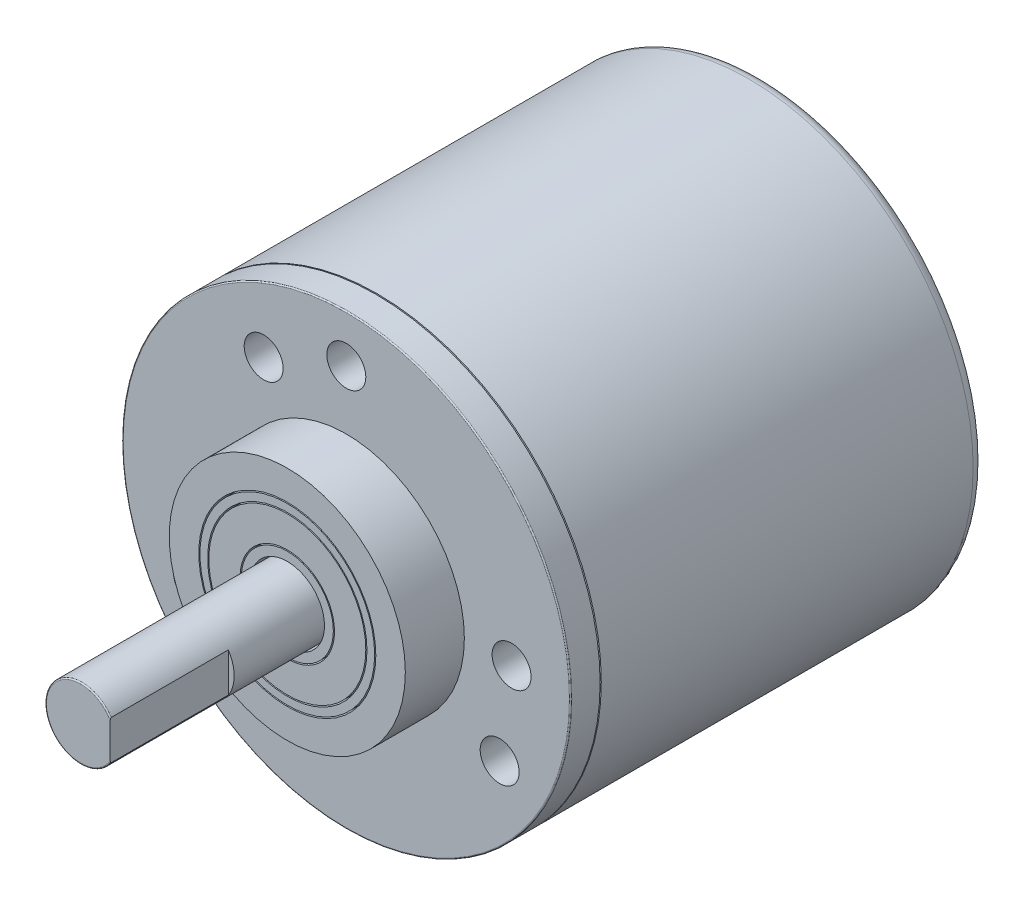
from build123d import *

# Parameters (mm, degrees)
SKETCH1_R             = 19
BOSS_EXTRUDE1_DEPTH   = 32.5
SKETCH2_R             = 18.5
BOSS_EXTRUDE2_DEPTH   = 0.1
SKETCH3_R             = 19
BOSS_EXTRUDE3_DEPTH   = 2.5
SKETCH4_R             = 10
BOSS_EXTRUDE4_DEPTH   = 5
SKETCH5_R             = 7.5
CUT_EXTRUDE1_DEPTH    = 3
SKETCH6_R             = 7.4
SKETCH6_R_2           = 6.75
BOSS_EXTRUDE6_DEPTH   = 3
SKETCH7_R             = 6.65
SKETCH7_R_2           = 4
BOSS_EXTRUDE7_DEPTH   = 3
SKETCH8_R             = 3.9
SKETCH8_R_2           = 3.15
BOSS_EXTRUDE8_DEPTH   = 3
SKETCH9_R             = 3
BOSS_EXTRUDE9_DEPTH   = 20.5
SKETCH11_W            = 10
SKETCH11_H            = 6
CUT_EXTRUDE2_DEPTH    = 0.5
FILLET1_R             = 0.1
FILLET2_R             = 0.1
FILLET3_R             = 1
M4_TAPPED_HOLE1_D     = 3.3
M4_TAPPED_HOLE1_DEPTH = 5
M4_TAPPED_HOLE1_TIP   = 0.991420021


with BuildPart() as part:
    # Sketch1 → Boss-Extrude1 (new body)
    with BuildSketch(Plane.XY):
        Circle(SKETCH1_R)
    extrude(amount=BOSS_EXTRUDE1_DEPTH)

    # Sketch2 → Boss-Extrude2 (add)
    with BuildSketch(Plane.XY.offset(32.5)):
        Circle(SKETCH2_R)
    extrude(amount=BOSS_EXTRUDE2_DEPTH)

    # Sketch3 → Boss-Extrude3 (add)
    with BuildSketch(Plane.XY.offset(32.6)):
        Circle(SKETCH3_R)
    extrude(amount=BOSS_EXTRUDE3_DEPTH)

    # Sketch4 → Boss-Extrude4 (add)
    with BuildSketch(Plane.XY.offset(35.1)):
        Circle(SKETCH4_R)
    extrude(amount=BOSS_EXTRUDE4_DEPTH)

    # Sketch5 → Cut-Extrude1 (cut)
    with BuildSketch(Plane.XY.offset(40.1)):
        Circle(SKETCH5_R)
    extrude(amount=-CUT_EXTRUDE1_DEPTH, mode=Mode.SUBTRACT)

    # Sketch6 → Boss-Extrude6 (add)
    with BuildSketch(Plane.XY.offset(37.1)):
        Circle(SKETCH6_R)
        Circle(SKETCH6_R_2, mode=Mode.SUBTRACT)
    extrude(amount=BOSS_EXTRUDE6_DEPTH)

    # Sketch7 → Boss-Extrude7 (add)
    with BuildSketch(Plane.XY.offset(37.1)):
        Circle(SKETCH7_R)
        Circle(SKETCH7_R_2, mode=Mode.SUBTRACT)
    extrude(amount=BOSS_EXTRUDE7_DEPTH)

    # Sketch8 → Boss-Extrude8 (add)
    with BuildSketch(Plane.XY.offset(37.1)):
        Circle(SKETCH8_R)
        Circle(SKETCH8_R_2, mode=Mode.SUBTRACT)
    extrude(amount=BOSS_EXTRUDE8_DEPTH)

    # Sketch9 → Boss-Extrude9 (add)
    with BuildSketch(Plane.XY.offset(37.1)):
        Circle(SKETCH9_R)
    extrude(amount=BOSS_EXTRUDE9_DEPTH)

    # Sketch11 → Cut-Extrude2 (cut)
    with BuildSketch(Plane(origin=(3, 0, 0), x_dir=(0, 0, -1), z_dir=(1, 0, 0))):
        with Locations((-52.6, 0)):
            Rectangle(SKETCH11_W, SKETCH11_H)
    extrude(amount=-CUT_EXTRUDE2_DEPTH, mode=Mode.SUBTRACT)

    # Fillet1
    fillet1_edges = [part.edges().sort_by_distance(p)[0] for p in [
        (-3, 0, 57.6),
    ]]
    fillet(fillet1_edges, radius=FILLET1_R)

    # Fillet2
    fillet2_edges = [part.edges().sort_by_distance(p)[0] for p in [
        (-19, 0, 35.1),
    ]]
    fillet(fillet2_edges, radius=FILLET2_R)

    # Fillet3
    fillet3_edges = [part.edges().sort_by_distance(p)[0] for p in [
        (-19, 0, 0),
    ]]
    fillet(fillet3_edges, radius=FILLET3_R)

    # M4 Tapped Hole1
    with Locations(Plane(origin=(-7, 12.124355653, 35.1), x_dir=(1, 0, 0), z_dir=(0, 0, 1))):
        with Locations((0, 0), (7, 2.875644347), (21, -12.124355653), (19.990381057, -19.624355653), (0, -24.248711306), (-5.990381057, -19.624355653)):
            Hole(M4_TAPPED_HOLE1_D / 2, depth=M4_TAPPED_HOLE1_DEPTH)
            with Locations((0, 0, -(M4_TAPPED_HOLE1_DEPTH + M4_TAPPED_HOLE1_TIP / 2))):  # 118° drill point
                Cone(0, M4_TAPPED_HOLE1_D / 2, M4_TAPPED_HOLE1_TIP, mode=Mode.SUBTRACT)


solid = part.part
